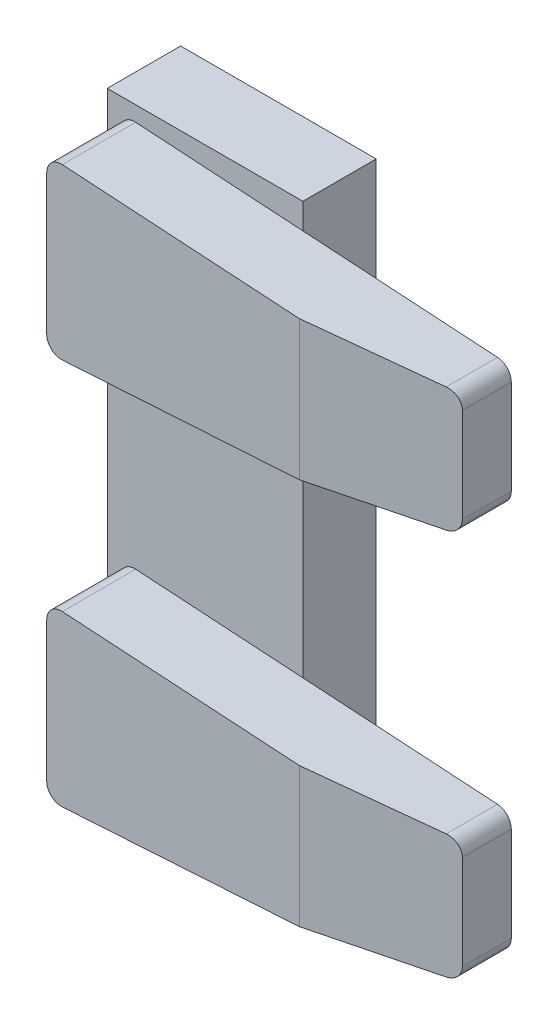
from build123d import *

# Parameters (mm, degrees)
SKETCH1_W             = 40
SKETCH1_H             = 120
BOSS_EXTRUDE1_DEPTH   = 15
BOSS_EXTRUDE2_DEPTH   = 15
BOSS_EXTRUDE2_2_DEPTH = 15
CHAMFER1_SIZE         = 5
CHAMFER1_SIZE2        = 28.356409098
CHAMFER2_SIZE         = 5
CHAMFER2_SIZE2        = 28.356409098
FILLET1_R             = 3
FILLET2_R             = 3


with BuildPart() as part:
    # Sketch1 → Boss-Extrude1 (new body)
    with BuildSketch(Plane.XY):
        with Locations((-25.25044303, 280.25981555)):
            Rectangle(SKETCH1_W, SKETCH1_H)
    extrude(amount=BOSS_EXTRUDE1_DEPTH)


with BuildPart() as body_2:
    # Sketch2 → Boss-Extrude2 (new body)
    with BuildSketch(Plane.XY.offset(15)):
        Polygon((-42.634929193, 258.205318026), (-42.634929193, 223.205318026), (37.365070807, 228.205318026), (37.365070807, 253.205318026), align=None)
    extrude(amount=BOSS_EXTRUDE2_DEPTH)

    # Chamfer2
    chamfer2_edges = [body_2.edges().sort_by_distance(p)[0] for p in [
        (37.365070807, 240.705318026, 30),
    ]]
    chamfer2_side = [body_2.faces().sort_by_distance(p)[0] for p in [
        (37.365070807, 240.705318026, 22.5),
    ]]
    chamfer(chamfer2_edges, length=CHAMFER2_SIZE, length2=CHAMFER2_SIZE2, reference=chamfer2_side[0])

    # Fillet1
    fillet1_edges = [body_2.edges().sort_by_distance(p)[0] for p in [
        (37.365070807, 253.205318026, 20),
        (37.365070807, 228.205318026, 20),
        (-42.634929193, 223.205318026, 22.5),
        (-42.634929193, 258.205318026, 22.5),
    ]]
    fillet(fillet1_edges, radius=FILLET1_R)


with BuildPart() as body_3:
    # Sketch2 → Boss-Extrude2 2 (new body)
    with BuildSketch(Plane.XY.offset(15)):
        Polygon((-42.634929193, 337.353227074), (-42.634929193, 302.353227074), (37.365070807, 307.353227074), (37.365070807, 332.353227074), align=None)
    extrude(amount=BOSS_EXTRUDE2_2_DEPTH)

    # Chamfer1
    chamfer1_edges = [body_3.edges().sort_by_distance(p)[0] for p in [
        (37.365070807, 319.853227074, 30),
    ]]
    chamfer1_side = [body_3.faces().sort_by_distance(p)[0] for p in [
        (37.365070807, 319.853227074, 22.5),
    ]]
    chamfer(chamfer1_edges, length=CHAMFER1_SIZE, length2=CHAMFER1_SIZE2, reference=chamfer1_side[0])

    # Fillet2
    fillet2_edges = [body_3.edges().sort_by_distance(p)[0] for p in [
        (37.365070807, 332.353227074, 20),
        (37.365070807, 307.353227074, 20),
        (-42.634929193, 302.353227074, 22.5),
        (-42.634929193, 337.353227074, 22.5),
    ]]
    fillet(fillet2_edges, radius=FILLET2_R)


solid = Compound([part.part, body_2.part, body_3.part])
